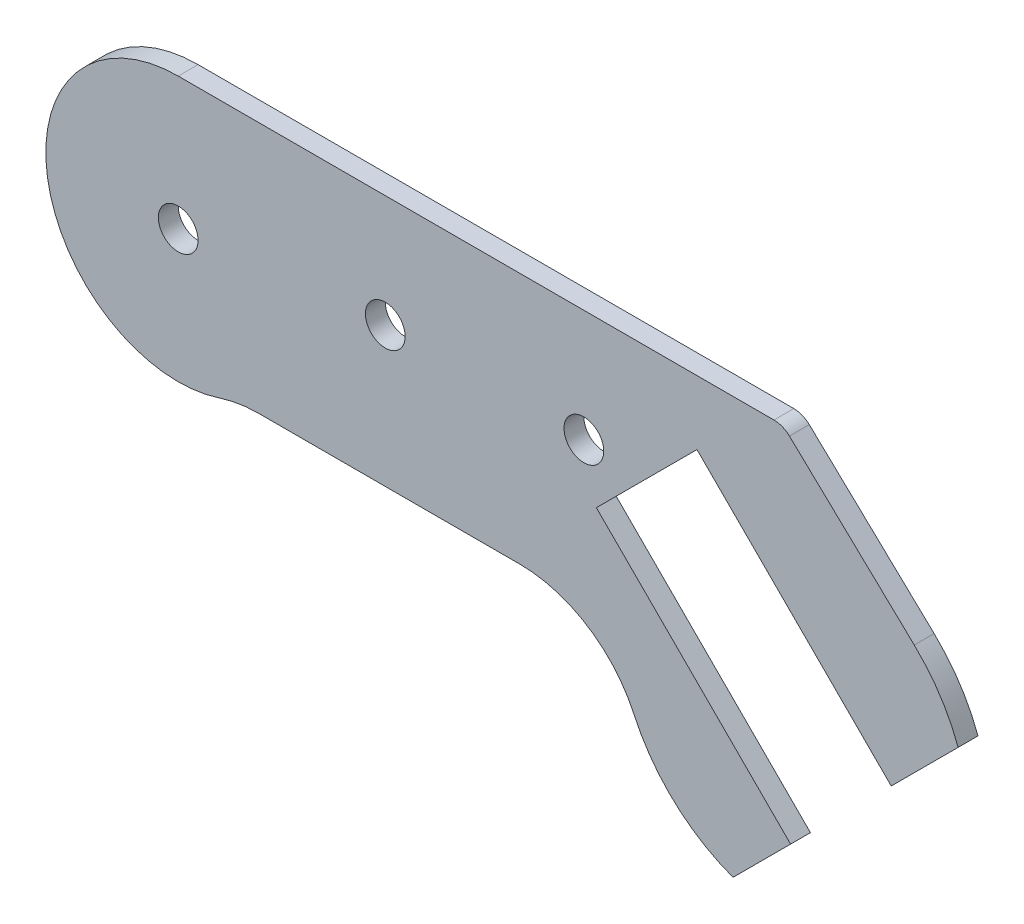
from build123d import *

# Parameters (mm, degrees)
SKETCH1_R           = 3
BOSS_EXTRUDE1_DEPTH = 3


with BuildPart() as part:
    # Sketch1 → Boss-Extrude1 (new body)
    with BuildSketch(Plane.XY):
        with BuildLine():
            Line((77.087645862, 14.761424984), (61.884850067, -0.441370812))
            Line((61.884850067, -0.441370812), (91.229781486, -29.786302231))
            Line((91.229781486, -29.786302231), (82.534788155, -38.481295563))
            ThreePointArc((82.534788155, -38.481295563), (73.691938632, -33.074158425), (67.599954135, -24.688405948))
            ThreePointArc((67.599954135, -24.688405948), (60.573216822, -16.61605207), (50.302224608, -13.608619059))
            Line((50.302224608, -13.608619059), (10.897118181, -13.608619059))
            ThreePointArc((10.897118181, -13.608619059), (7.888998842, -13.847714786), (4.956418896, -14.558997838))
            ThreePointArc((4.956418896, -14.558997838), (-21.031882132, 1.283456288), (-1.283000467, 24.442834864))
            Line((-1.283000467, 24.442834864), (88.716999533, 24.442834864))
            ThreePointArc((88.716999533, 24.442834864), (89.976795131, 24.200731926), (91.057113295, 23.508914432))
            Line((91.057113295, 23.508914432), (109.912759821, 5.607389522))
            ThreePointArc((109.912759821, 5.607389522), (113.808768074, 0.948896759), (116.541784176, -4.474299542))
            Line((116.541784176, -4.474299542), (106.432577282, -14.583506436))
            Line((106.432577282, -14.583506436), (77.087645862, 14.761424984))
        make_face()
        with Locations((30, 7.5)):
            Circle(SKETCH1_R, mode=Mode.SUBTRACT)
        with Locations((-1.283000467, 4.442834864)):
            Circle(SKETCH1_R, mode=Mode.SUBTRACT)
        with Locations((60, 7.5)):
            Circle(SKETCH1_R, mode=Mode.SUBTRACT)
    extrude(amount=BOSS_EXTRUDE1_DEPTH)


solid = part.part
